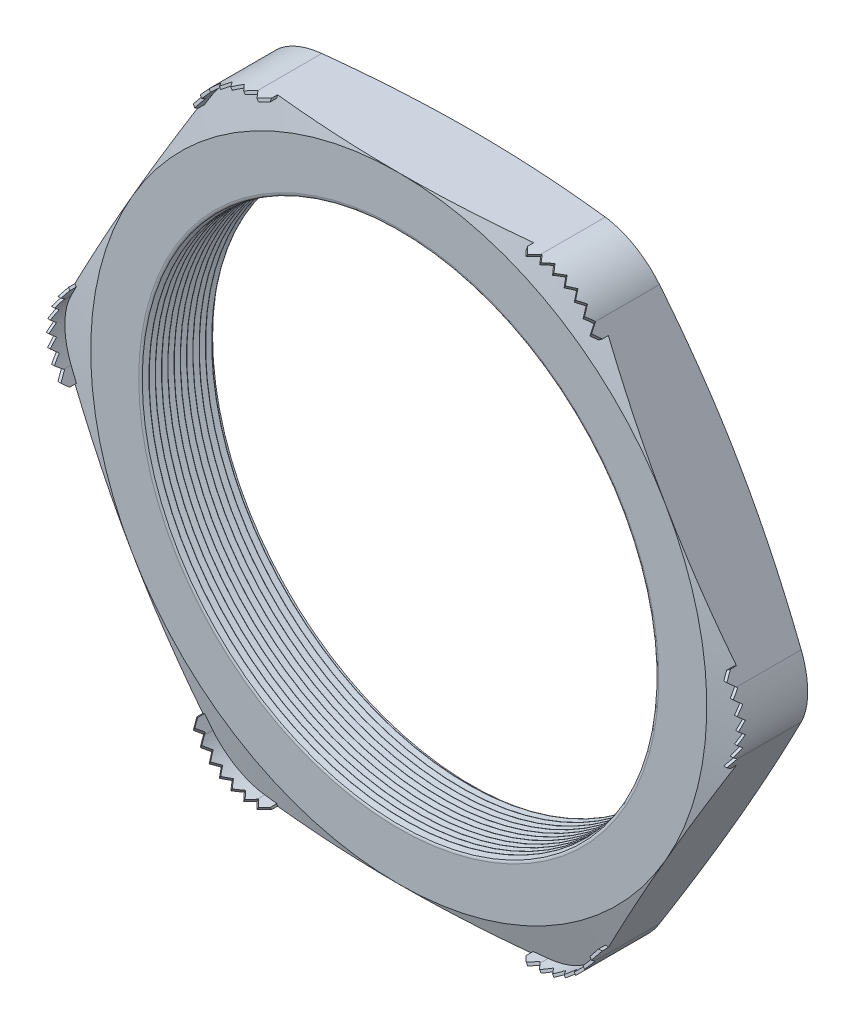
from build123d import *

# Parameters (mm, degrees)
SKETCH1_R          = 12.446
EXTRUDE1_DEPTH     = 3.556
FILLET1_R          = 3.048
FILLET3_R          = 0.2032
LPATTERN1_COUNT    = 12
LPATTERN1_PITCH    = 0.3048
SKETCH4_OUTSIDE_W  = 78.716
SKETCH4_OUTSIDE_H  = 75.022
SKETCH4_OUTSIDE_R  = 14.986
CUT_EXTRUDE1_DEPTH = 4.556
CUT_EXTRUDE1_DRAFT = -75
SKETCH5_OUTSIDE_W  = 78.716
SKETCH5_OUTSIDE_H  = 75.022
SKETCH5_OUTSIDE_R  = 14.986
CUT_EXTRUDE2_DEPTH = 4.5560001
CUT_EXTRUDE2_DRAFT = -75
EXTRUDE2_START     = -0.494853
EXTRUDE2_DEPTH     = 1.333053
CUT_EXTRUDE4_DEPTH = 6.41038912
CIRPATTERN1_COUNT  = 6
CIRPATTERN2_COUNT  = 6


with BuildPart() as part:
    # Sketch1 → Extrude1 (new body)
    with BuildSketch(Plane.XY):
        Polygon((-17.304342268, 0), (-8.652171134, -14.986), (8.652171134, -14.986), (17.304342268, 0), (8.652171134, 14.986), (-8.652171134, 14.986), align=None)
        Circle(SKETCH1_R, mode=Mode.SUBTRACT)
    extrude(amount=EXTRUDE1_DEPTH)

    # Fillet1
    fillet1_edges = [part.edges().sort_by_distance(p)[0] for p in [
        (17.304342268, 0, 1.778),
        (8.652171134, -14.986, 1.778),
        (-8.652171134, -14.986, 1.778),
        (-17.304342268, 0, 1.778),
        (-8.652171134, 14.986, 1.778),
        (8.652171134, 14.986, 1.778),
    ]]
    fillet(fillet1_edges, radius=FILLET1_R)

    # Fillet3
    fillet3_edges = [part.edges().sort_by_distance(p)[0] for p in [
        (-12.446, 0, 0),
        (-12.446, 0, 3.556),
    ]]
    fillet(fillet3_edges, radius=FILLET3_R)

    # Sketch3 → Cut-Revolve1 (revolve, cut)
    with BuildSketch(Plane(origin=(0, 0, 0), x_dir=(1, 0, 0), z_dir=(0, 1, 0))):
        Polygon((-12.446, -3.556), (-12.446, -3.262706063), (-12.7, -3.409353032), align=None)
    cut_revolve1 = revolve(axis=Axis((0, 0, 3.556), (0, 0, -1)), mode=Mode.SUBTRACT)

    # LPattern1: Cut-Revolve1 ×12
    with Locations(*[(0, 0, -i * LPATTERN1_PITCH) for i in range(1, LPATTERN1_COUNT)]):
        add(cut_revolve1, mode=Mode.SUBTRACT)


with BuildPart() as cut_extrude1_tool:
    # Sketch4 outside → Cut-Extrude1 (with draft: the straight prism first)
    with BuildSketch(Plane(origin=(0, 0, 0), x_dir=(-1, 0, 0), z_dir=(0, 0, -1))):
        Rectangle(SKETCH4_OUTSIDE_W, SKETCH4_OUTSIDE_H)
        Circle(SKETCH4_OUTSIDE_R, mode=Mode.SUBTRACT)
    extrude(amount=-CUT_EXTRUDE1_DEPTH)
    # Cut-Extrude1: the draft: its side faces are tilted about the plane it starts from
    cut_extrude1_sides = [cut_extrude1_tool.faces().sort_by_distance(p)[0] for p in [
        (0, -37.511, 2.278),
        (-39.358, 0, 2.278),
        (0, 37.511, 2.278),
        (39.358, 0, 2.278),
        (14.986, 0, 2.278),
    ]]
    draft(cut_extrude1_sides, Plane(origin=(0, 0, 0), x_dir=(-1, 0, 0), z_dir=(0, 0, -1)), CUT_EXTRUDE1_DRAFT)


with BuildPart() as part_1:
    add(part.part)

    # Cut-Extrude1: cut by cut_extrude1_tool
    add(cut_extrude1_tool.part, mode=Mode.SUBTRACT)


with BuildPart() as cut_extrude2_tool:
    # Sketch5 outside → Cut-Extrude2 (with draft: the straight prism first)
    with BuildSketch(Plane.XY.offset(3.556)):
        Rectangle(SKETCH5_OUTSIDE_W, SKETCH5_OUTSIDE_H)
        Circle(SKETCH5_OUTSIDE_R, mode=Mode.SUBTRACT)
    extrude(amount=-CUT_EXTRUDE2_DEPTH)
    # Cut-Extrude2: the draft: its side faces are tilted about the plane it starts from
    cut_extrude2_sides = [cut_extrude2_tool.faces().sort_by_distance(p)[0] for p in [
        (0, -37.511, 1.27799995),
        (39.358, 0, 1.27799995),
        (0, 37.511, 1.27799995),
        (-39.358, 0, 1.27799995),
        (-14.986, 0, 1.27799995),
    ]]
    draft(cut_extrude2_sides, Plane.XY.offset(3.556), CUT_EXTRUDE2_DRAFT)


with BuildPart() as part_2:
    add(part_1.part)

    # Cut-Extrude2: cut by cut_extrude2_tool
    add(cut_extrude2_tool.part, mode=Mode.SUBTRACT)

    # Sketch2 → Extrude2 (add)
    with BuildSketch(Plane.XY.offset(3.556).offset(EXTRUDE2_START)):
        with BuildLine():
            Line((-6.892407514, 14.986), (-6.232007514, 14.986))
            Line((-6.232007514, 14.986), (-6.232007514, 14.859))
            Line((-6.232007514, 14.859), (-6.892407514, 14.859))
            ThreePointArc((-6.892407514, 14.859), (-8.352907514, 14.467660204), (-9.422067718, 13.3985))
            Line((-9.422067718, 13.3985), (-9.752267718, 12.826576823))
            Line((-9.752267718, 12.826576823), (-9.862252944, 12.890076823))
            Line((-9.862252944, 12.890076823), (-9.532052944, 13.462))
            ThreePointArc((-9.532052944, 13.462), (-8.416407514, 14.577645431), (-6.892407514, 14.986))
        make_face()
    extrude2 = extrude(amount=EXTRUDE2_DEPTH)

    # Sketch7 → Cut-Extrude4 (cut, through all)
    with BuildSketch(Plane(origin=(-7.992137616, 13.842788412, 0), x_dir=(0.866025404, 0.5, 0), z_dir=(0.5, -0.866025404, 0))):
        Polygon((-2.095923177, 3.51409), (-1.791123177, 3.866134), (-1.486323177, 3.51409), (-1.2192, 3.866134), (-0.9144, 3.51409), (-0.6096, 3.866134), (-0.3048, 3.51409), (0, 3.866134), (0.3048, 3.51409), (0.6096, 3.866134), (0.9144, 3.51409), (1.2192, 3.866134), (1.524, 3.51409), (1.791123177, 3.866134), (2.095923177, 3.51409), (2.095923177, 4.3942), (-2.095923177, 4.3942), align=None)
    cut_extrude4 = extrude(amount=-CUT_EXTRUDE4_DEPTH, mode=Mode.SUBTRACT)

    # CirPattern1: Extrude2 ×6 about axis
    cirpattern1_axis = Axis((0, 0, 0), (0, 0, 1))
    for i in range(1, CIRPATTERN1_COUNT):
        add(extrude2.rotate(cirpattern1_axis, i * 360 / CIRPATTERN1_COUNT))

    # CirPattern2: Cut-Extrude4 ×6 about axis
    cirpattern2_axis = Axis((0, 0, 0), (0, 0, 1))
    for i in range(1, CIRPATTERN2_COUNT):
        add(cut_extrude4.rotate(cirpattern2_axis, i * 360 / CIRPATTERN2_COUNT), mode=Mode.SUBTRACT)


solid = part_2.part
